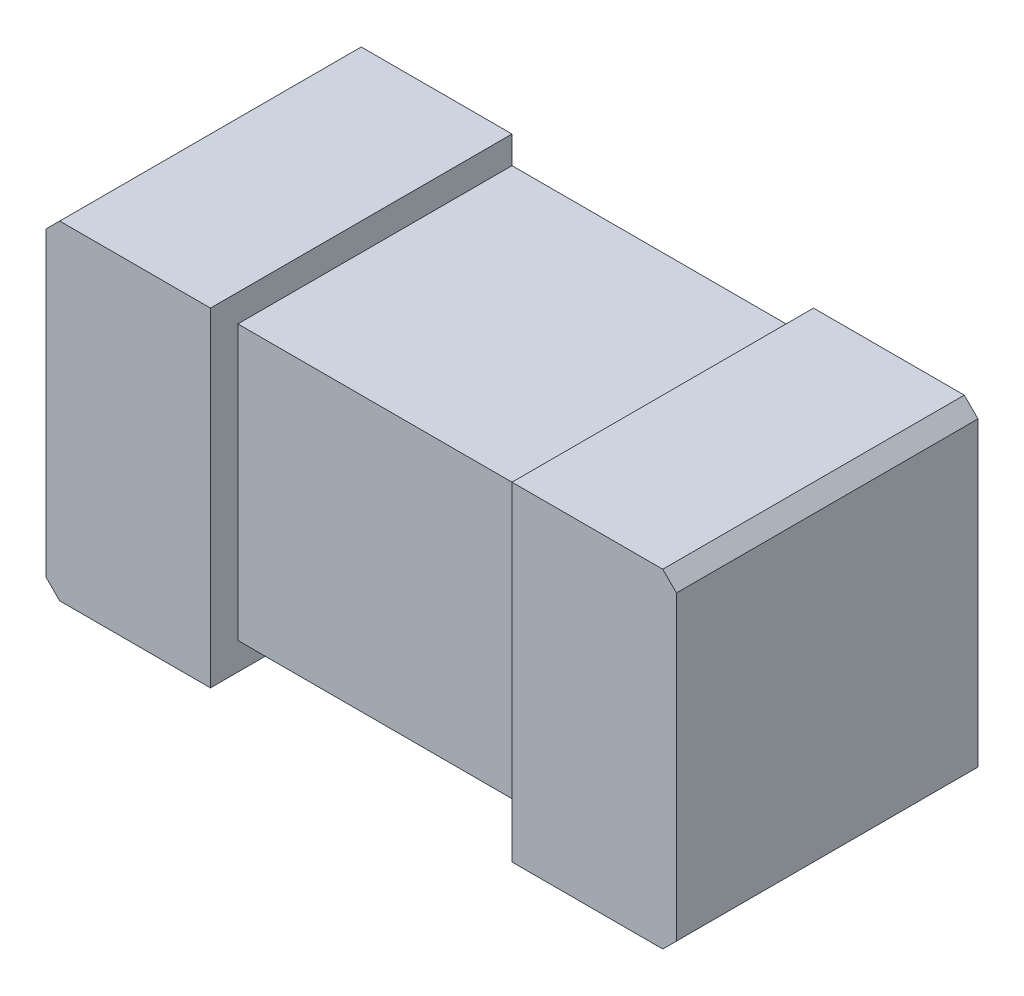
from build123d import *

# Parameters (mm, degrees)
EXTRUDE1_DEPTH     = 0.55
SKETCH1_W          = 0.55
SKETCH1_H          = 0.05
CUT_EXTRUDE1_DEPTH = 10
SKETCH2_W          = 0.55
SKETCH2_H          = 0.05
CUT_EXTRUDE2_DEPTH = 10


with BuildPart() as part:
    # COMPONENT_OUTLINE → Extrude1 (new body)
    with BuildSketch(Plane.XY):
        Polygon((0.55, 0.3), (-0.55, 0.3), (-0.575, 0.275), (-0.575, -0.275), (-0.55, -0.3), (0.55, -0.3), (0.575, -0.275), (0.575, 0.275), align=None)
    extrude(amount=EXTRUDE1_DEPTH)

    # Sketch1 → Cut-Extrude1 (cut)
    with BuildSketch(Plane.XY.offset(0.55)):
        with Locations((0, -0.275)):
            Rectangle(SKETCH1_W, SKETCH1_H)
        with Locations((0, 0.275)):
            Rectangle(SKETCH1_W, SKETCH1_H)
    extrude(amount=-CUT_EXTRUDE1_DEPTH, mode=Mode.SUBTRACT)

    # Sketch2 → Cut-Extrude2 (cut)
    with BuildSketch(Plane.XZ.offset(0.25)):
        with Locations((0, 0.525)):
            Rectangle(SKETCH2_W, SKETCH2_H)
    extrude(amount=-CUT_EXTRUDE2_DEPTH, mode=Mode.SUBTRACT)


solid = part.part
